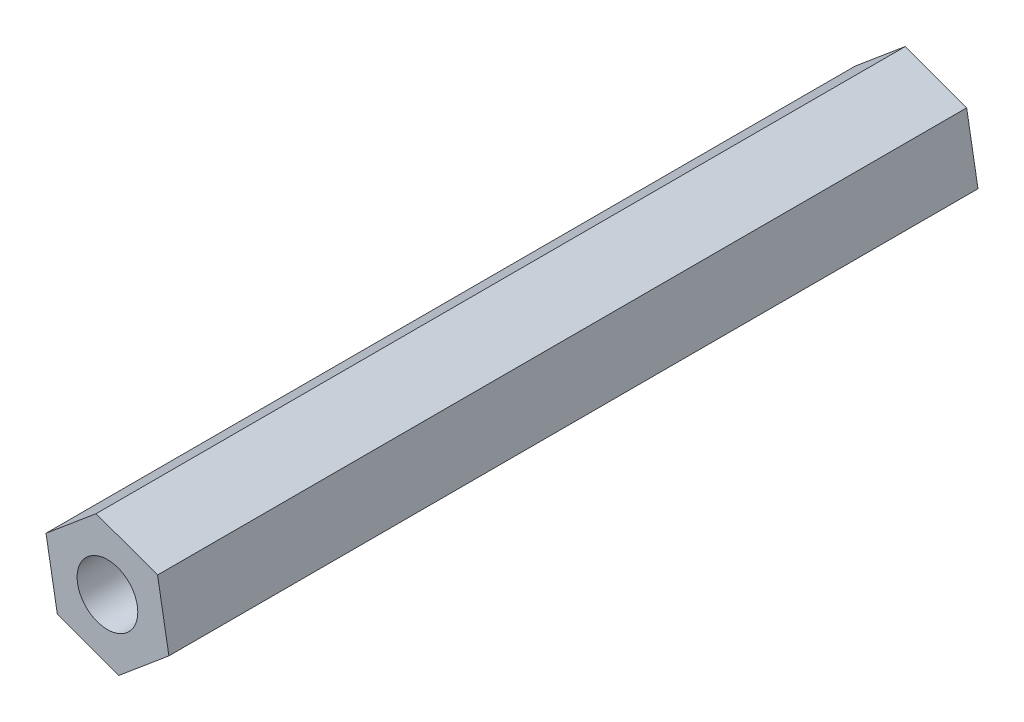
from build123d import *

# Parameters (mm, degrees)
SKETCH_1_R      = 1.5
EXTRUDE_1_DEPTH = 40


with BuildPart() as part:
    # 草图1 → 凸台-拉伸1 (new body)
    with BuildSketch(Plane.XY):
        Polygon((-129.741556691, -57.086424359), (-127.263938912, -55.009228299), (-127.824034578, -51.824950331), (-130.861748025, -50.717868423), (-133.339365804, -52.795064483), (-132.779270137, -55.979342451), align=None)
        with Locations((-130.301652358, -53.902146391)):
            Circle(SKETCH_1_R, mode=Mode.SUBTRACT)
    extrude(amount=EXTRUDE_1_DEPTH)


solid = part.part
